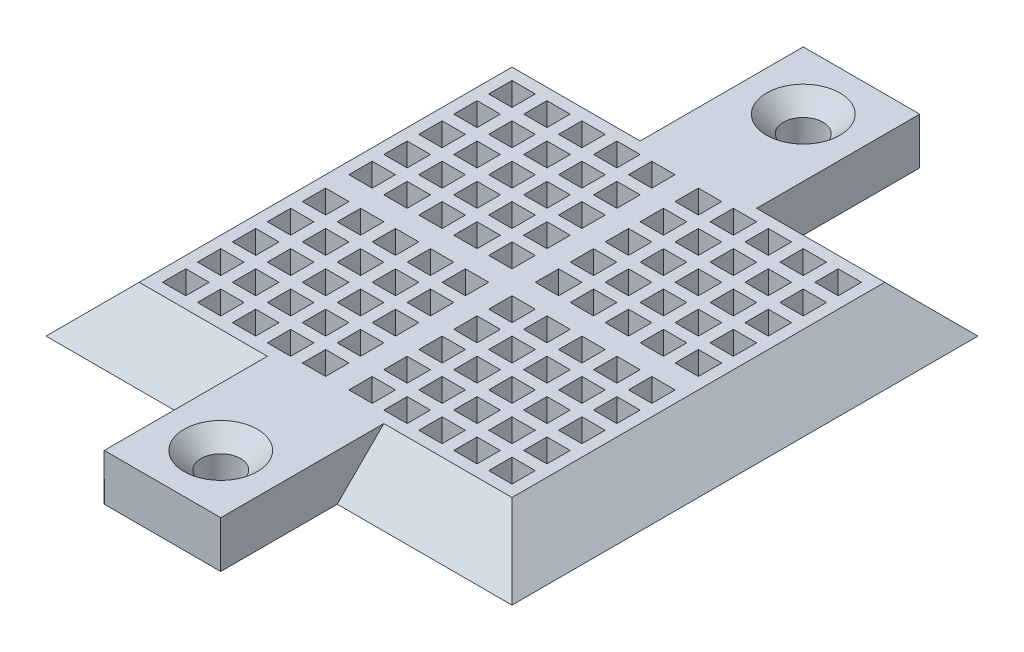
from build123d import *

# Parameters (mm, degrees)
SKETCH_1_W                        = 10
SKETCH_1_H                        = 10
SKETCH_1_W_2                      = 40
SKETCH_1_H_2                      = 40
EXTRUDE_2_DEPTH                   = 4
DRAFT_2_ANGLE                     = -45
HOLE_WIZARD_M31_D                 = 3.4
HOLE_WIZARD_M31_DEPTH             = 4
HOLE_WIZARD_M31_CSINK_D           = 6.3
HOLE_WIZARD_M31_CSINK_ANGLE       = 90
SKETCH_5_W                        = 2
SKETCH_5_H                        = 2
CUT_EXTRUDE_1_DEPTH               = 4
PATTERN_LINEAR_1_COUNT            = 5
PATTERN_LINEAR_1_PITCH            = 3
PATTERN_LINEAR_1_COUNT_DIR2       = 5
PATTERN_LINEAR_1_PITCH_DIR2       = 3
PATTERN_LINEAR_2_COUNT            = 2
PATTERN_LINEAR_2_PITCH            = 16
PATTERN_LINEAR_2_COUNT_DIR2       = 2
PATTERN_LINEAR_2_PITCH_DIR2       = 16
PATTERN_LINEAR_2_COPY_1_SKETCH_W  = 2
PATTERN_LINEAR_2_COPY_1_SKETCH_H  = 2
PATTERN_LINEAR_2_COPY_1_DEPTH     = 4
PATTERN_LINEAR_2_COPY_2_SKETCH_W  = 2
PATTERN_LINEAR_2_COPY_2_SKETCH_H  = 2
PATTERN_LINEAR_2_COPY_2_DEPTH     = 4
PATTERN_LINEAR_2_COPY_3_SKETCH_W  = 2
PATTERN_LINEAR_2_COPY_3_SKETCH_H  = 2
PATTERN_LINEAR_2_COPY_3_DEPTH     = 4
PATTERN_LINEAR_2_COPY_4_SKETCH_W  = 2
PATTERN_LINEAR_2_COPY_4_SKETCH_H  = 2
PATTERN_LINEAR_2_COPY_4_DEPTH     = 4
PATTERN_LINEAR_2_COPY_5_SKETCH_W  = 2
PATTERN_LINEAR_2_COPY_5_SKETCH_H  = 2
PATTERN_LINEAR_2_COPY_5_DEPTH     = 4
PATTERN_LINEAR_2_COPY_6_SKETCH_W  = 2
PATTERN_LINEAR_2_COPY_6_SKETCH_H  = 2
PATTERN_LINEAR_2_COPY_6_DEPTH     = 4
PATTERN_LINEAR_2_COPY_7_SKETCH_W  = 2
PATTERN_LINEAR_2_COPY_7_SKETCH_H  = 2
PATTERN_LINEAR_2_COPY_7_DEPTH     = 4
PATTERN_LINEAR_2_COPY_8_SKETCH_W  = 2
PATTERN_LINEAR_2_COPY_8_SKETCH_H  = 2
PATTERN_LINEAR_2_COPY_8_DEPTH     = 4
PATTERN_LINEAR_2_COPY_9_SKETCH_W  = 2
PATTERN_LINEAR_2_COPY_9_SKETCH_H  = 2
PATTERN_LINEAR_2_COPY_9_DEPTH     = 4
PATTERN_LINEAR_2_COPY_10_SKETCH_W = 2
PATTERN_LINEAR_2_COPY_10_SKETCH_H = 2
PATTERN_LINEAR_2_COPY_10_DEPTH    = 4
PATTERN_LINEAR_2_COPY_11_SKETCH_W = 2
PATTERN_LINEAR_2_COPY_11_SKETCH_H = 2
PATTERN_LINEAR_2_COPY_11_DEPTH    = 4
PATTERN_LINEAR_2_COPY_12_SKETCH_W = 2
PATTERN_LINEAR_2_COPY_12_SKETCH_H = 2
PATTERN_LINEAR_2_COPY_12_DEPTH    = 4
PATTERN_LINEAR_2_COPY_13_SKETCH_W = 2
PATTERN_LINEAR_2_COPY_13_SKETCH_H = 2
PATTERN_LINEAR_2_COPY_13_DEPTH    = 4
PATTERN_LINEAR_2_COPY_14_SKETCH_W = 2
PATTERN_LINEAR_2_COPY_14_SKETCH_H = 2
PATTERN_LINEAR_2_COPY_14_DEPTH    = 4
PATTERN_LINEAR_2_COPY_15_SKETCH_W = 2
PATTERN_LINEAR_2_COPY_15_SKETCH_H = 2
PATTERN_LINEAR_2_COPY_15_DEPTH    = 4
PATTERN_LINEAR_2_COPY_16_SKETCH_W = 2
PATTERN_LINEAR_2_COPY_16_SKETCH_H = 2
PATTERN_LINEAR_2_COPY_16_DEPTH    = 4
PATTERN_LINEAR_2_COPY_17_SKETCH_W = 2
PATTERN_LINEAR_2_COPY_17_SKETCH_H = 2
PATTERN_LINEAR_2_COPY_17_DEPTH    = 4
PATTERN_LINEAR_2_COPY_18_SKETCH_W = 2
PATTERN_LINEAR_2_COPY_18_SKETCH_H = 2
PATTERN_LINEAR_2_COPY_18_DEPTH    = 4
PATTERN_LINEAR_2_COPY_19_SKETCH_W = 2
PATTERN_LINEAR_2_COPY_19_SKETCH_H = 2
PATTERN_LINEAR_2_COPY_19_DEPTH    = 4
PATTERN_LINEAR_2_COPY_20_SKETCH_W = 2
PATTERN_LINEAR_2_COPY_20_SKETCH_H = 2
PATTERN_LINEAR_2_COPY_20_DEPTH    = 4
PATTERN_LINEAR_2_COPY_21_SKETCH_W = 2
PATTERN_LINEAR_2_COPY_21_SKETCH_H = 2
PATTERN_LINEAR_2_COPY_21_DEPTH    = 4
PATTERN_LINEAR_2_COPY_22_SKETCH_W = 2
PATTERN_LINEAR_2_COPY_22_SKETCH_H = 2
PATTERN_LINEAR_2_COPY_22_DEPTH    = 4
PATTERN_LINEAR_2_COPY_23_SKETCH_W = 2
PATTERN_LINEAR_2_COPY_23_SKETCH_H = 2
PATTERN_LINEAR_2_COPY_23_DEPTH    = 4
PATTERN_LINEAR_2_COPY_24_SKETCH_W = 2
PATTERN_LINEAR_2_COPY_24_SKETCH_H = 2
PATTERN_LINEAR_2_COPY_24_DEPTH    = 4
PATTERN_LINEAR_2_COPY_25_SKETCH_W = 2
PATTERN_LINEAR_2_COPY_25_SKETCH_H = 2
PATTERN_LINEAR_2_COPY_25_DEPTH    = 4
PATTERN_LINEAR_2_COPY_26_SKETCH_W = 2
PATTERN_LINEAR_2_COPY_26_SKETCH_H = 2
PATTERN_LINEAR_2_COPY_26_DEPTH    = 4
PATTERN_LINEAR_2_COPY_27_SKETCH_W = 2
PATTERN_LINEAR_2_COPY_27_SKETCH_H = 2
PATTERN_LINEAR_2_COPY_27_DEPTH    = 4
PATTERN_LINEAR_2_COPY_28_SKETCH_W = 2
PATTERN_LINEAR_2_COPY_28_SKETCH_H = 2
PATTERN_LINEAR_2_COPY_28_DEPTH    = 4
PATTERN_LINEAR_2_COPY_29_SKETCH_W = 2
PATTERN_LINEAR_2_COPY_29_SKETCH_H = 2
PATTERN_LINEAR_2_COPY_29_DEPTH    = 4
PATTERN_LINEAR_2_COPY_30_SKETCH_W = 2
PATTERN_LINEAR_2_COPY_30_SKETCH_H = 2
PATTERN_LINEAR_2_COPY_30_DEPTH    = 4
PATTERN_LINEAR_2_COPY_31_SKETCH_W = 2
PATTERN_LINEAR_2_COPY_31_SKETCH_H = 2
PATTERN_LINEAR_2_COPY_31_DEPTH    = 4
PATTERN_LINEAR_2_COPY_32_SKETCH_W = 2
PATTERN_LINEAR_2_COPY_32_SKETCH_H = 2
PATTERN_LINEAR_2_COPY_32_DEPTH    = 4
PATTERN_LINEAR_2_COPY_33_SKETCH_W = 2
PATTERN_LINEAR_2_COPY_33_SKETCH_H = 2
PATTERN_LINEAR_2_COPY_33_DEPTH    = 4
PATTERN_LINEAR_2_COPY_34_SKETCH_W = 2
PATTERN_LINEAR_2_COPY_34_SKETCH_H = 2
PATTERN_LINEAR_2_COPY_34_DEPTH    = 4
PATTERN_LINEAR_2_COPY_35_SKETCH_W = 2
PATTERN_LINEAR_2_COPY_35_SKETCH_H = 2
PATTERN_LINEAR_2_COPY_35_DEPTH    = 4
PATTERN_LINEAR_2_COPY_36_SKETCH_W = 2
PATTERN_LINEAR_2_COPY_36_SKETCH_H = 2
PATTERN_LINEAR_2_COPY_36_DEPTH    = 4
PATTERN_LINEAR_2_COPY_37_SKETCH_W = 2
PATTERN_LINEAR_2_COPY_37_SKETCH_H = 2
PATTERN_LINEAR_2_COPY_37_DEPTH    = 4
PATTERN_LINEAR_2_COPY_38_SKETCH_W = 2
PATTERN_LINEAR_2_COPY_38_SKETCH_H = 2
PATTERN_LINEAR_2_COPY_38_DEPTH    = 4
PATTERN_LINEAR_2_COPY_39_SKETCH_W = 2
PATTERN_LINEAR_2_COPY_39_SKETCH_H = 2
PATTERN_LINEAR_2_COPY_39_DEPTH    = 4
PATTERN_LINEAR_2_COPY_40_SKETCH_W = 2
PATTERN_LINEAR_2_COPY_40_SKETCH_H = 2
PATTERN_LINEAR_2_COPY_40_DEPTH    = 4
PATTERN_LINEAR_2_COPY_41_SKETCH_W = 2
PATTERN_LINEAR_2_COPY_41_SKETCH_H = 2
PATTERN_LINEAR_2_COPY_41_DEPTH    = 4
PATTERN_LINEAR_2_COPY_42_SKETCH_W = 2
PATTERN_LINEAR_2_COPY_42_SKETCH_H = 2
PATTERN_LINEAR_2_COPY_42_DEPTH    = 4
PATTERN_LINEAR_2_COPY_43_SKETCH_W = 2
PATTERN_LINEAR_2_COPY_43_SKETCH_H = 2
PATTERN_LINEAR_2_COPY_43_DEPTH    = 4
PATTERN_LINEAR_2_COPY_44_SKETCH_W = 2
PATTERN_LINEAR_2_COPY_44_SKETCH_H = 2
PATTERN_LINEAR_2_COPY_44_DEPTH    = 4
PATTERN_LINEAR_2_COPY_45_SKETCH_W = 2
PATTERN_LINEAR_2_COPY_45_SKETCH_H = 2
PATTERN_LINEAR_2_COPY_45_DEPTH    = 4
PATTERN_LINEAR_2_COPY_46_SKETCH_W = 2
PATTERN_LINEAR_2_COPY_46_SKETCH_H = 2
PATTERN_LINEAR_2_COPY_46_DEPTH    = 4
PATTERN_LINEAR_2_COPY_47_SKETCH_W = 2
PATTERN_LINEAR_2_COPY_47_SKETCH_H = 2
PATTERN_LINEAR_2_COPY_47_DEPTH    = 4
PATTERN_LINEAR_2_COPY_48_SKETCH_W = 2
PATTERN_LINEAR_2_COPY_48_SKETCH_H = 2
PATTERN_LINEAR_2_COPY_48_DEPTH    = 4
PATTERN_LINEAR_2_COPY_49_SKETCH_W = 2
PATTERN_LINEAR_2_COPY_49_SKETCH_H = 2
PATTERN_LINEAR_2_COPY_49_DEPTH    = 4
PATTERN_LINEAR_2_COPY_50_SKETCH_W = 2
PATTERN_LINEAR_2_COPY_50_SKETCH_H = 2
PATTERN_LINEAR_2_COPY_50_DEPTH    = 4
PATTERN_LINEAR_2_COPY_51_SKETCH_W = 2
PATTERN_LINEAR_2_COPY_51_SKETCH_H = 2
PATTERN_LINEAR_2_COPY_51_DEPTH    = 4
PATTERN_LINEAR_2_COPY_52_SKETCH_W = 2
PATTERN_LINEAR_2_COPY_52_SKETCH_H = 2
PATTERN_LINEAR_2_COPY_52_DEPTH    = 4
PATTERN_LINEAR_2_COPY_53_SKETCH_W = 2
PATTERN_LINEAR_2_COPY_53_SKETCH_H = 2
PATTERN_LINEAR_2_COPY_53_DEPTH    = 4
PATTERN_LINEAR_2_COPY_54_SKETCH_W = 2
PATTERN_LINEAR_2_COPY_54_SKETCH_H = 2
PATTERN_LINEAR_2_COPY_54_DEPTH    = 4
PATTERN_LINEAR_2_COPY_55_SKETCH_W = 2
PATTERN_LINEAR_2_COPY_55_SKETCH_H = 2
PATTERN_LINEAR_2_COPY_55_DEPTH    = 4
PATTERN_LINEAR_2_COPY_56_SKETCH_W = 2
PATTERN_LINEAR_2_COPY_56_SKETCH_H = 2
PATTERN_LINEAR_2_COPY_56_DEPTH    = 4
PATTERN_LINEAR_2_COPY_57_SKETCH_W = 2
PATTERN_LINEAR_2_COPY_57_SKETCH_H = 2
PATTERN_LINEAR_2_COPY_57_DEPTH    = 4
PATTERN_LINEAR_2_COPY_58_SKETCH_W = 2
PATTERN_LINEAR_2_COPY_58_SKETCH_H = 2
PATTERN_LINEAR_2_COPY_58_DEPTH    = 4
PATTERN_LINEAR_2_COPY_59_SKETCH_W = 2
PATTERN_LINEAR_2_COPY_59_SKETCH_H = 2
PATTERN_LINEAR_2_COPY_59_DEPTH    = 4
PATTERN_LINEAR_2_COPY_60_SKETCH_W = 2
PATTERN_LINEAR_2_COPY_60_SKETCH_H = 2
PATTERN_LINEAR_2_COPY_60_DEPTH    = 4
PATTERN_LINEAR_2_COPY_61_SKETCH_W = 2
PATTERN_LINEAR_2_COPY_61_SKETCH_H = 2
PATTERN_LINEAR_2_COPY_61_DEPTH    = 4
PATTERN_LINEAR_2_COPY_62_SKETCH_W = 2
PATTERN_LINEAR_2_COPY_62_SKETCH_H = 2
PATTERN_LINEAR_2_COPY_62_DEPTH    = 4
PATTERN_LINEAR_2_COPY_63_SKETCH_W = 2
PATTERN_LINEAR_2_COPY_63_SKETCH_H = 2
PATTERN_LINEAR_2_COPY_63_DEPTH    = 4
PATTERN_LINEAR_2_COPY_64_SKETCH_W = 2
PATTERN_LINEAR_2_COPY_64_SKETCH_H = 2
PATTERN_LINEAR_2_COPY_64_DEPTH    = 4
PATTERN_LINEAR_2_COPY_65_SKETCH_W = 2
PATTERN_LINEAR_2_COPY_65_SKETCH_H = 2
PATTERN_LINEAR_2_COPY_65_DEPTH    = 4
PATTERN_LINEAR_2_COPY_66_SKETCH_W = 2
PATTERN_LINEAR_2_COPY_66_SKETCH_H = 2
PATTERN_LINEAR_2_COPY_66_DEPTH    = 4
PATTERN_LINEAR_2_COPY_67_SKETCH_W = 2
PATTERN_LINEAR_2_COPY_67_SKETCH_H = 2
PATTERN_LINEAR_2_COPY_67_DEPTH    = 4
PATTERN_LINEAR_2_COPY_68_SKETCH_W = 2
PATTERN_LINEAR_2_COPY_68_SKETCH_H = 2
PATTERN_LINEAR_2_COPY_68_DEPTH    = 4
PATTERN_LINEAR_2_COPY_69_SKETCH_W = 2
PATTERN_LINEAR_2_COPY_69_SKETCH_H = 2
PATTERN_LINEAR_2_COPY_69_DEPTH    = 4
PATTERN_LINEAR_2_COPY_70_SKETCH_W = 2
PATTERN_LINEAR_2_COPY_70_SKETCH_H = 2
PATTERN_LINEAR_2_COPY_70_DEPTH    = 4
PATTERN_LINEAR_2_COPY_71_SKETCH_W = 2
PATTERN_LINEAR_2_COPY_71_SKETCH_H = 2
PATTERN_LINEAR_2_COPY_71_DEPTH    = 4
PATTERN_LINEAR_2_COPY_72_SKETCH_W = 2
PATTERN_LINEAR_2_COPY_72_SKETCH_H = 2
PATTERN_LINEAR_2_COPY_72_DEPTH    = 4


with BuildPart() as part:
    # Эскиз1 → Бобышка-Вытянуть2 (new body)
    with BuildSketch(Plane(origin=(0, 0, 0), x_dir=(1, 0, 0), z_dir=(0, 1, 0))):
        with Locations((0, 25)):
            Rectangle(SKETCH_1_W, SKETCH_1_H)
        Rectangle(SKETCH_1_W_2, SKETCH_1_H_2)
        with Locations((0, -25)):
            Rectangle(SKETCH_1_W, SKETCH_1_H)
    extrude(amount=EXTRUDE_2_DEPTH)

    # Уклон2
    draft_2_faces = [part.faces().sort_by_distance(p)[0] for p in [
        (-12.5, 2, 20),
        (-20, 2, 0),
        (-12.5, 2, -20),
        (12.5, 2, -20),
        (20, 2, 0),
        (12.5, 2, 20),
    ]]
    draft(draft_2_faces, Plane(origin=(0, 0, 0), x_dir=(0, 0, -1), z_dir=(0, -1, 0)), DRAFT_2_ANGLE)

    # Зенковка для винта с потайной головкой M31
    with Locations(Plane(origin=(0, 4, -25), x_dir=(0, 0, 1), z_dir=(0, 1, 0))):
        with Locations((0, 0)):
            hole_wizard_m31 = CounterSinkHole(HOLE_WIZARD_M31_D / 2, HOLE_WIZARD_M31_CSINK_D / 2, depth=HOLE_WIZARD_M31_DEPTH, counter_sink_angle=HOLE_WIZARD_M31_CSINK_ANGLE)

    # Зеркальное отражение1: Зенковка для винта с потайной головкой M31 across plane
    add(hole_wizard_m31.mirror(Plane.XY), mode=Mode.SUBTRACT)

    # Эскиз5 → Вырез-Вытянуть1 (cut)
    with BuildSketch(Plane(origin=(0, 4, 0), x_dir=(1, 0, 0), z_dir=(0, 1, 0))):
        with Locations((14, 14)):
            Rectangle(SKETCH_5_W, SKETCH_5_H)
    cut_extrude_1 = extrude(amount=-CUT_EXTRUDE_1_DEPTH, mode=Mode.SUBTRACT)

    # Линейный массив1: Cut-Extrude 1 5 × 5
    with Locations(*[(-i * PATTERN_LINEAR_1_PITCH, 0, j * PATTERN_LINEAR_1_PITCH_DIR2) for i in range(PATTERN_LINEAR_1_COUNT) for j in range(PATTERN_LINEAR_1_COUNT_DIR2) if (i, j) != (0, 0)]):
        add(cut_extrude_1, mode=Mode.SUBTRACT)

    # Линейный массив2: Cut-Extrude 1 2 × 2
    with Locations(*[(-i * PATTERN_LINEAR_2_PITCH, 0, j * PATTERN_LINEAR_2_PITCH_DIR2) for i in range(PATTERN_LINEAR_2_COUNT) for j in range(PATTERN_LINEAR_2_COUNT_DIR2) if (i, j) != (0, 0)]):
        add(cut_extrude_1, mode=Mode.SUBTRACT)

    # Линейный массив2 copy 1 sketch → Линейный массив2 copy 1 (cut)
    with BuildSketch(Plane(origin=(0, 4, 19), x_dir=(1, 0, 0), z_dir=(0, 1, 0))):
        with Locations((14, 14)):
            Rectangle(PATTERN_LINEAR_2_COPY_1_SKETCH_W, PATTERN_LINEAR_2_COPY_1_SKETCH_H)
    extrude(amount=-PATTERN_LINEAR_2_COPY_1_DEPTH, mode=Mode.SUBTRACT)

    # Линейный массив2 copy 2 sketch → Линейный массив2 copy 2 (cut)
    with BuildSketch(Plane(origin=(-16, 4, 3), x_dir=(1, 0, 0), z_dir=(0, 1, 0))):
        with Locations((14, 14)):
            Rectangle(PATTERN_LINEAR_2_COPY_2_SKETCH_W, PATTERN_LINEAR_2_COPY_2_SKETCH_H)
    extrude(amount=-PATTERN_LINEAR_2_COPY_2_DEPTH, mode=Mode.SUBTRACT)

    # Линейный массив2 copy 3 sketch → Линейный массив2 copy 3 (cut)
    with BuildSketch(Plane(origin=(-16, 4, 19), x_dir=(1, 0, 0), z_dir=(0, 1, 0))):
        with Locations((14, 14)):
            Rectangle(PATTERN_LINEAR_2_COPY_3_SKETCH_W, PATTERN_LINEAR_2_COPY_3_SKETCH_H)
    extrude(amount=-PATTERN_LINEAR_2_COPY_3_DEPTH, mode=Mode.SUBTRACT)

    # Линейный массив2 copy 4 sketch → Линейный массив2 copy 4 (cut)
    with BuildSketch(Plane(origin=(0, 4, 22), x_dir=(1, 0, 0), z_dir=(0, 1, 0))):
        with Locations((14, 14)):
            Rectangle(PATTERN_LINEAR_2_COPY_4_SKETCH_W, PATTERN_LINEAR_2_COPY_4_SKETCH_H)
    extrude(amount=-PATTERN_LINEAR_2_COPY_4_DEPTH, mode=Mode.SUBTRACT)

    # Линейный массив2 copy 5 sketch → Линейный массив2 copy 5 (cut)
    with BuildSketch(Plane(origin=(-16, 4, 6), x_dir=(1, 0, 0), z_dir=(0, 1, 0))):
        with Locations((14, 14)):
            Rectangle(PATTERN_LINEAR_2_COPY_5_SKETCH_W, PATTERN_LINEAR_2_COPY_5_SKETCH_H)
    extrude(amount=-PATTERN_LINEAR_2_COPY_5_DEPTH, mode=Mode.SUBTRACT)

    # Линейный массив2 copy 6 sketch → Линейный массив2 copy 6 (cut)
    with BuildSketch(Plane(origin=(-16, 4, 22), x_dir=(1, 0, 0), z_dir=(0, 1, 0))):
        with Locations((14, 14)):
            Rectangle(PATTERN_LINEAR_2_COPY_6_SKETCH_W, PATTERN_LINEAR_2_COPY_6_SKETCH_H)
    extrude(amount=-PATTERN_LINEAR_2_COPY_6_DEPTH, mode=Mode.SUBTRACT)

    # Линейный массив2 copy 7 sketch → Линейный массив2 copy 7 (cut)
    with BuildSketch(Plane(origin=(0, 4, 25), x_dir=(1, 0, 0), z_dir=(0, 1, 0))):
        with Locations((14, 14)):
            Rectangle(PATTERN_LINEAR_2_COPY_7_SKETCH_W, PATTERN_LINEAR_2_COPY_7_SKETCH_H)
    extrude(amount=-PATTERN_LINEAR_2_COPY_7_DEPTH, mode=Mode.SUBTRACT)

    # Линейный массив2 copy 8 sketch → Линейный массив2 copy 8 (cut)
    with BuildSketch(Plane(origin=(-16, 4, 9), x_dir=(1, 0, 0), z_dir=(0, 1, 0))):
        with Locations((14, 14)):
            Rectangle(PATTERN_LINEAR_2_COPY_8_SKETCH_W, PATTERN_LINEAR_2_COPY_8_SKETCH_H)
    extrude(amount=-PATTERN_LINEAR_2_COPY_8_DEPTH, mode=Mode.SUBTRACT)

    # Линейный массив2 copy 9 sketch → Линейный массив2 copy 9 (cut)
    with BuildSketch(Plane(origin=(-16, 4, 25), x_dir=(1, 0, 0), z_dir=(0, 1, 0))):
        with Locations((14, 14)):
            Rectangle(PATTERN_LINEAR_2_COPY_9_SKETCH_W, PATTERN_LINEAR_2_COPY_9_SKETCH_H)
    extrude(amount=-PATTERN_LINEAR_2_COPY_9_DEPTH, mode=Mode.SUBTRACT)

    # Линейный массив2 copy 10 sketch → Линейный массив2 copy 10 (cut)
    with BuildSketch(Plane(origin=(0, 4, 28), x_dir=(1, 0, 0), z_dir=(0, 1, 0))):
        with Locations((14, 14)):
            Rectangle(PATTERN_LINEAR_2_COPY_10_SKETCH_W, PATTERN_LINEAR_2_COPY_10_SKETCH_H)
    extrude(amount=-PATTERN_LINEAR_2_COPY_10_DEPTH, mode=Mode.SUBTRACT)

    # Линейный массив2 copy 11 sketch → Линейный массив2 copy 11 (cut)
    with BuildSketch(Plane(origin=(-16, 4, 12), x_dir=(1, 0, 0), z_dir=(0, 1, 0))):
        with Locations((14, 14)):
            Rectangle(PATTERN_LINEAR_2_COPY_11_SKETCH_W, PATTERN_LINEAR_2_COPY_11_SKETCH_H)
    extrude(amount=-PATTERN_LINEAR_2_COPY_11_DEPTH, mode=Mode.SUBTRACT)

    # Линейный массив2 copy 12 sketch → Линейный массив2 copy 12 (cut)
    with BuildSketch(Plane(origin=(-16, 4, 28), x_dir=(1, 0, 0), z_dir=(0, 1, 0))):
        with Locations((14, 14)):
            Rectangle(PATTERN_LINEAR_2_COPY_12_SKETCH_W, PATTERN_LINEAR_2_COPY_12_SKETCH_H)
    extrude(amount=-PATTERN_LINEAR_2_COPY_12_DEPTH, mode=Mode.SUBTRACT)

    # Линейный массив2 copy 13 sketch → Линейный массив2 copy 13 (cut)
    with BuildSketch(Plane(origin=(-3, 4, 16), x_dir=(1, 0, 0), z_dir=(0, 1, 0))):
        with Locations((14, 14)):
            Rectangle(PATTERN_LINEAR_2_COPY_13_SKETCH_W, PATTERN_LINEAR_2_COPY_13_SKETCH_H)
    extrude(amount=-PATTERN_LINEAR_2_COPY_13_DEPTH, mode=Mode.SUBTRACT)

    # Линейный массив2 copy 14 sketch → Линейный массив2 copy 14 (cut)
    with BuildSketch(Plane(origin=(-19, 4, 0), x_dir=(1, 0, 0), z_dir=(0, 1, 0))):
        with Locations((14, 14)):
            Rectangle(PATTERN_LINEAR_2_COPY_14_SKETCH_W, PATTERN_LINEAR_2_COPY_14_SKETCH_H)
    extrude(amount=-PATTERN_LINEAR_2_COPY_14_DEPTH, mode=Mode.SUBTRACT)

    # Линейный массив2 copy 15 sketch → Линейный массив2 copy 15 (cut)
    with BuildSketch(Plane(origin=(-19, 4, 16), x_dir=(1, 0, 0), z_dir=(0, 1, 0))):
        with Locations((14, 14)):
            Rectangle(PATTERN_LINEAR_2_COPY_15_SKETCH_W, PATTERN_LINEAR_2_COPY_15_SKETCH_H)
    extrude(amount=-PATTERN_LINEAR_2_COPY_15_DEPTH, mode=Mode.SUBTRACT)

    # Линейный массив2 copy 16 sketch → Линейный массив2 copy 16 (cut)
    with BuildSketch(Plane(origin=(-3, 4, 19), x_dir=(1, 0, 0), z_dir=(0, 1, 0))):
        with Locations((14, 14)):
            Rectangle(PATTERN_LINEAR_2_COPY_16_SKETCH_W, PATTERN_LINEAR_2_COPY_16_SKETCH_H)
    extrude(amount=-PATTERN_LINEAR_2_COPY_16_DEPTH, mode=Mode.SUBTRACT)

    # Линейный массив2 copy 17 sketch → Линейный массив2 copy 17 (cut)
    with BuildSketch(Plane(origin=(-19, 4, 3), x_dir=(1, 0, 0), z_dir=(0, 1, 0))):
        with Locations((14, 14)):
            Rectangle(PATTERN_LINEAR_2_COPY_17_SKETCH_W, PATTERN_LINEAR_2_COPY_17_SKETCH_H)
    extrude(amount=-PATTERN_LINEAR_2_COPY_17_DEPTH, mode=Mode.SUBTRACT)

    # Линейный массив2 copy 18 sketch → Линейный массив2 copy 18 (cut)
    with BuildSketch(Plane(origin=(-19, 4, 19), x_dir=(1, 0, 0), z_dir=(0, 1, 0))):
        with Locations((14, 14)):
            Rectangle(PATTERN_LINEAR_2_COPY_18_SKETCH_W, PATTERN_LINEAR_2_COPY_18_SKETCH_H)
    extrude(amount=-PATTERN_LINEAR_2_COPY_18_DEPTH, mode=Mode.SUBTRACT)

    # Линейный массив2 copy 19 sketch → Линейный массив2 copy 19 (cut)
    with BuildSketch(Plane(origin=(-3, 4, 22), x_dir=(1, 0, 0), z_dir=(0, 1, 0))):
        with Locations((14, 14)):
            Rectangle(PATTERN_LINEAR_2_COPY_19_SKETCH_W, PATTERN_LINEAR_2_COPY_19_SKETCH_H)
    extrude(amount=-PATTERN_LINEAR_2_COPY_19_DEPTH, mode=Mode.SUBTRACT)

    # Линейный массив2 copy 20 sketch → Линейный массив2 copy 20 (cut)
    with BuildSketch(Plane(origin=(-19, 4, 6), x_dir=(1, 0, 0), z_dir=(0, 1, 0))):
        with Locations((14, 14)):
            Rectangle(PATTERN_LINEAR_2_COPY_20_SKETCH_W, PATTERN_LINEAR_2_COPY_20_SKETCH_H)
    extrude(amount=-PATTERN_LINEAR_2_COPY_20_DEPTH, mode=Mode.SUBTRACT)

    # Линейный массив2 copy 21 sketch → Линейный массив2 copy 21 (cut)
    with BuildSketch(Plane(origin=(-19, 4, 22), x_dir=(1, 0, 0), z_dir=(0, 1, 0))):
        with Locations((14, 14)):
            Rectangle(PATTERN_LINEAR_2_COPY_21_SKETCH_W, PATTERN_LINEAR_2_COPY_21_SKETCH_H)
    extrude(amount=-PATTERN_LINEAR_2_COPY_21_DEPTH, mode=Mode.SUBTRACT)

    # Линейный массив2 copy 22 sketch → Линейный массив2 copy 22 (cut)
    with BuildSketch(Plane(origin=(-3, 4, 25), x_dir=(1, 0, 0), z_dir=(0, 1, 0))):
        with Locations((14, 14)):
            Rectangle(PATTERN_LINEAR_2_COPY_22_SKETCH_W, PATTERN_LINEAR_2_COPY_22_SKETCH_H)
    extrude(amount=-PATTERN_LINEAR_2_COPY_22_DEPTH, mode=Mode.SUBTRACT)

    # Линейный массив2 copy 23 sketch → Линейный массив2 copy 23 (cut)
    with BuildSketch(Plane(origin=(-19, 4, 9), x_dir=(1, 0, 0), z_dir=(0, 1, 0))):
        with Locations((14, 14)):
            Rectangle(PATTERN_LINEAR_2_COPY_23_SKETCH_W, PATTERN_LINEAR_2_COPY_23_SKETCH_H)
    extrude(amount=-PATTERN_LINEAR_2_COPY_23_DEPTH, mode=Mode.SUBTRACT)

    # Линейный массив2 copy 24 sketch → Линейный массив2 copy 24 (cut)
    with BuildSketch(Plane(origin=(-19, 4, 25), x_dir=(1, 0, 0), z_dir=(0, 1, 0))):
        with Locations((14, 14)):
            Rectangle(PATTERN_LINEAR_2_COPY_24_SKETCH_W, PATTERN_LINEAR_2_COPY_24_SKETCH_H)
    extrude(amount=-PATTERN_LINEAR_2_COPY_24_DEPTH, mode=Mode.SUBTRACT)

    # Линейный массив2 copy 25 sketch → Линейный массив2 copy 25 (cut)
    with BuildSketch(Plane(origin=(-3, 4, 28), x_dir=(1, 0, 0), z_dir=(0, 1, 0))):
        with Locations((14, 14)):
            Rectangle(PATTERN_LINEAR_2_COPY_25_SKETCH_W, PATTERN_LINEAR_2_COPY_25_SKETCH_H)
    extrude(amount=-PATTERN_LINEAR_2_COPY_25_DEPTH, mode=Mode.SUBTRACT)

    # Линейный массив2 copy 26 sketch → Линейный массив2 copy 26 (cut)
    with BuildSketch(Plane(origin=(-19, 4, 12), x_dir=(1, 0, 0), z_dir=(0, 1, 0))):
        with Locations((14, 14)):
            Rectangle(PATTERN_LINEAR_2_COPY_26_SKETCH_W, PATTERN_LINEAR_2_COPY_26_SKETCH_H)
    extrude(amount=-PATTERN_LINEAR_2_COPY_26_DEPTH, mode=Mode.SUBTRACT)

    # Линейный массив2 copy 27 sketch → Линейный массив2 copy 27 (cut)
    with BuildSketch(Plane(origin=(-19, 4, 28), x_dir=(1, 0, 0), z_dir=(0, 1, 0))):
        with Locations((14, 14)):
            Rectangle(PATTERN_LINEAR_2_COPY_27_SKETCH_W, PATTERN_LINEAR_2_COPY_27_SKETCH_H)
    extrude(amount=-PATTERN_LINEAR_2_COPY_27_DEPTH, mode=Mode.SUBTRACT)

    # Линейный массив2 copy 28 sketch → Линейный массив2 copy 28 (cut)
    with BuildSketch(Plane(origin=(-6, 4, 16), x_dir=(1, 0, 0), z_dir=(0, 1, 0))):
        with Locations((14, 14)):
            Rectangle(PATTERN_LINEAR_2_COPY_28_SKETCH_W, PATTERN_LINEAR_2_COPY_28_SKETCH_H)
    extrude(amount=-PATTERN_LINEAR_2_COPY_28_DEPTH, mode=Mode.SUBTRACT)

    # Линейный массив2 copy 29 sketch → Линейный массив2 copy 29 (cut)
    with BuildSketch(Plane(origin=(-22, 4, 0), x_dir=(1, 0, 0), z_dir=(0, 1, 0))):
        with Locations((14, 14)):
            Rectangle(PATTERN_LINEAR_2_COPY_29_SKETCH_W, PATTERN_LINEAR_2_COPY_29_SKETCH_H)
    extrude(amount=-PATTERN_LINEAR_2_COPY_29_DEPTH, mode=Mode.SUBTRACT)

    # Линейный массив2 copy 30 sketch → Линейный массив2 copy 30 (cut)
    with BuildSketch(Plane(origin=(-22, 4, 16), x_dir=(1, 0, 0), z_dir=(0, 1, 0))):
        with Locations((14, 14)):
            Rectangle(PATTERN_LINEAR_2_COPY_30_SKETCH_W, PATTERN_LINEAR_2_COPY_30_SKETCH_H)
    extrude(amount=-PATTERN_LINEAR_2_COPY_30_DEPTH, mode=Mode.SUBTRACT)

    # Линейный массив2 copy 31 sketch → Линейный массив2 copy 31 (cut)
    with BuildSketch(Plane(origin=(-6, 4, 19), x_dir=(1, 0, 0), z_dir=(0, 1, 0))):
        with Locations((14, 14)):
            Rectangle(PATTERN_LINEAR_2_COPY_31_SKETCH_W, PATTERN_LINEAR_2_COPY_31_SKETCH_H)
    extrude(amount=-PATTERN_LINEAR_2_COPY_31_DEPTH, mode=Mode.SUBTRACT)

    # Линейный массив2 copy 32 sketch → Линейный массив2 copy 32 (cut)
    with BuildSketch(Plane(origin=(-22, 4, 3), x_dir=(1, 0, 0), z_dir=(0, 1, 0))):
        with Locations((14, 14)):
            Rectangle(PATTERN_LINEAR_2_COPY_32_SKETCH_W, PATTERN_LINEAR_2_COPY_32_SKETCH_H)
    extrude(amount=-PATTERN_LINEAR_2_COPY_32_DEPTH, mode=Mode.SUBTRACT)

    # Линейный массив2 copy 33 sketch → Линейный массив2 copy 33 (cut)
    with BuildSketch(Plane(origin=(-22, 4, 19), x_dir=(1, 0, 0), z_dir=(0, 1, 0))):
        with Locations((14, 14)):
            Rectangle(PATTERN_LINEAR_2_COPY_33_SKETCH_W, PATTERN_LINEAR_2_COPY_33_SKETCH_H)
    extrude(amount=-PATTERN_LINEAR_2_COPY_33_DEPTH, mode=Mode.SUBTRACT)

    # Линейный массив2 copy 34 sketch → Линейный массив2 copy 34 (cut)
    with BuildSketch(Plane(origin=(-6, 4, 22), x_dir=(1, 0, 0), z_dir=(0, 1, 0))):
        with Locations((14, 14)):
            Rectangle(PATTERN_LINEAR_2_COPY_34_SKETCH_W, PATTERN_LINEAR_2_COPY_34_SKETCH_H)
    extrude(amount=-PATTERN_LINEAR_2_COPY_34_DEPTH, mode=Mode.SUBTRACT)

    # Линейный массив2 copy 35 sketch → Линейный массив2 copy 35 (cut)
    with BuildSketch(Plane(origin=(-22, 4, 6), x_dir=(1, 0, 0), z_dir=(0, 1, 0))):
        with Locations((14, 14)):
            Rectangle(PATTERN_LINEAR_2_COPY_35_SKETCH_W, PATTERN_LINEAR_2_COPY_35_SKETCH_H)
    extrude(amount=-PATTERN_LINEAR_2_COPY_35_DEPTH, mode=Mode.SUBTRACT)

    # Линейный массив2 copy 36 sketch → Линейный массив2 copy 36 (cut)
    with BuildSketch(Plane(origin=(-22, 4, 22), x_dir=(1, 0, 0), z_dir=(0, 1, 0))):
        with Locations((14, 14)):
            Rectangle(PATTERN_LINEAR_2_COPY_36_SKETCH_W, PATTERN_LINEAR_2_COPY_36_SKETCH_H)
    extrude(amount=-PATTERN_LINEAR_2_COPY_36_DEPTH, mode=Mode.SUBTRACT)

    # Линейный массив2 copy 37 sketch → Линейный массив2 copy 37 (cut)
    with BuildSketch(Plane(origin=(-6, 4, 25), x_dir=(1, 0, 0), z_dir=(0, 1, 0))):
        with Locations((14, 14)):
            Rectangle(PATTERN_LINEAR_2_COPY_37_SKETCH_W, PATTERN_LINEAR_2_COPY_37_SKETCH_H)
    extrude(amount=-PATTERN_LINEAR_2_COPY_37_DEPTH, mode=Mode.SUBTRACT)

    # Линейный массив2 copy 38 sketch → Линейный массив2 copy 38 (cut)
    with BuildSketch(Plane(origin=(-22, 4, 9), x_dir=(1, 0, 0), z_dir=(0, 1, 0))):
        with Locations((14, 14)):
            Rectangle(PATTERN_LINEAR_2_COPY_38_SKETCH_W, PATTERN_LINEAR_2_COPY_38_SKETCH_H)
    extrude(amount=-PATTERN_LINEAR_2_COPY_38_DEPTH, mode=Mode.SUBTRACT)

    # Линейный массив2 copy 39 sketch → Линейный массив2 copy 39 (cut)
    with BuildSketch(Plane(origin=(-22, 4, 25), x_dir=(1, 0, 0), z_dir=(0, 1, 0))):
        with Locations((14, 14)):
            Rectangle(PATTERN_LINEAR_2_COPY_39_SKETCH_W, PATTERN_LINEAR_2_COPY_39_SKETCH_H)
    extrude(amount=-PATTERN_LINEAR_2_COPY_39_DEPTH, mode=Mode.SUBTRACT)

    # Линейный массив2 copy 40 sketch → Линейный массив2 copy 40 (cut)
    with BuildSketch(Plane(origin=(-6, 4, 28), x_dir=(1, 0, 0), z_dir=(0, 1, 0))):
        with Locations((14, 14)):
            Rectangle(PATTERN_LINEAR_2_COPY_40_SKETCH_W, PATTERN_LINEAR_2_COPY_40_SKETCH_H)
    extrude(amount=-PATTERN_LINEAR_2_COPY_40_DEPTH, mode=Mode.SUBTRACT)

    # Линейный массив2 copy 41 sketch → Линейный массив2 copy 41 (cut)
    with BuildSketch(Plane(origin=(-22, 4, 12), x_dir=(1, 0, 0), z_dir=(0, 1, 0))):
        with Locations((14, 14)):
            Rectangle(PATTERN_LINEAR_2_COPY_41_SKETCH_W, PATTERN_LINEAR_2_COPY_41_SKETCH_H)
    extrude(amount=-PATTERN_LINEAR_2_COPY_41_DEPTH, mode=Mode.SUBTRACT)

    # Линейный массив2 copy 42 sketch → Линейный массив2 copy 42 (cut)
    with BuildSketch(Plane(origin=(-22, 4, 28), x_dir=(1, 0, 0), z_dir=(0, 1, 0))):
        with Locations((14, 14)):
            Rectangle(PATTERN_LINEAR_2_COPY_42_SKETCH_W, PATTERN_LINEAR_2_COPY_42_SKETCH_H)
    extrude(amount=-PATTERN_LINEAR_2_COPY_42_DEPTH, mode=Mode.SUBTRACT)

    # Линейный массив2 copy 43 sketch → Линейный массив2 copy 43 (cut)
    with BuildSketch(Plane(origin=(-9, 4, 16), x_dir=(1, 0, 0), z_dir=(0, 1, 0))):
        with Locations((14, 14)):
            Rectangle(PATTERN_LINEAR_2_COPY_43_SKETCH_W, PATTERN_LINEAR_2_COPY_43_SKETCH_H)
    extrude(amount=-PATTERN_LINEAR_2_COPY_43_DEPTH, mode=Mode.SUBTRACT)

    # Линейный массив2 copy 44 sketch → Линейный массив2 copy 44 (cut)
    with BuildSketch(Plane(origin=(-25, 4, 0), x_dir=(1, 0, 0), z_dir=(0, 1, 0))):
        with Locations((14, 14)):
            Rectangle(PATTERN_LINEAR_2_COPY_44_SKETCH_W, PATTERN_LINEAR_2_COPY_44_SKETCH_H)
    extrude(amount=-PATTERN_LINEAR_2_COPY_44_DEPTH, mode=Mode.SUBTRACT)

    # Линейный массив2 copy 45 sketch → Линейный массив2 copy 45 (cut)
    with BuildSketch(Plane(origin=(-25, 4, 16), x_dir=(1, 0, 0), z_dir=(0, 1, 0))):
        with Locations((14, 14)):
            Rectangle(PATTERN_LINEAR_2_COPY_45_SKETCH_W, PATTERN_LINEAR_2_COPY_45_SKETCH_H)
    extrude(amount=-PATTERN_LINEAR_2_COPY_45_DEPTH, mode=Mode.SUBTRACT)

    # Линейный массив2 copy 46 sketch → Линейный массив2 copy 46 (cut)
    with BuildSketch(Plane(origin=(-9, 4, 19), x_dir=(1, 0, 0), z_dir=(0, 1, 0))):
        with Locations((14, 14)):
            Rectangle(PATTERN_LINEAR_2_COPY_46_SKETCH_W, PATTERN_LINEAR_2_COPY_46_SKETCH_H)
    extrude(amount=-PATTERN_LINEAR_2_COPY_46_DEPTH, mode=Mode.SUBTRACT)

    # Линейный массив2 copy 47 sketch → Линейный массив2 copy 47 (cut)
    with BuildSketch(Plane(origin=(-25, 4, 3), x_dir=(1, 0, 0), z_dir=(0, 1, 0))):
        with Locations((14, 14)):
            Rectangle(PATTERN_LINEAR_2_COPY_47_SKETCH_W, PATTERN_LINEAR_2_COPY_47_SKETCH_H)
    extrude(amount=-PATTERN_LINEAR_2_COPY_47_DEPTH, mode=Mode.SUBTRACT)

    # Линейный массив2 copy 48 sketch → Линейный массив2 copy 48 (cut)
    with BuildSketch(Plane(origin=(-25, 4, 19), x_dir=(1, 0, 0), z_dir=(0, 1, 0))):
        with Locations((14, 14)):
            Rectangle(PATTERN_LINEAR_2_COPY_48_SKETCH_W, PATTERN_LINEAR_2_COPY_48_SKETCH_H)
    extrude(amount=-PATTERN_LINEAR_2_COPY_48_DEPTH, mode=Mode.SUBTRACT)

    # Линейный массив2 copy 49 sketch → Линейный массив2 copy 49 (cut)
    with BuildSketch(Plane(origin=(-9, 4, 22), x_dir=(1, 0, 0), z_dir=(0, 1, 0))):
        with Locations((14, 14)):
            Rectangle(PATTERN_LINEAR_2_COPY_49_SKETCH_W, PATTERN_LINEAR_2_COPY_49_SKETCH_H)
    extrude(amount=-PATTERN_LINEAR_2_COPY_49_DEPTH, mode=Mode.SUBTRACT)

    # Линейный массив2 copy 50 sketch → Линейный массив2 copy 50 (cut)
    with BuildSketch(Plane(origin=(-25, 4, 6), x_dir=(1, 0, 0), z_dir=(0, 1, 0))):
        with Locations((14, 14)):
            Rectangle(PATTERN_LINEAR_2_COPY_50_SKETCH_W, PATTERN_LINEAR_2_COPY_50_SKETCH_H)
    extrude(amount=-PATTERN_LINEAR_2_COPY_50_DEPTH, mode=Mode.SUBTRACT)

    # Линейный массив2 copy 51 sketch → Линейный массив2 copy 51 (cut)
    with BuildSketch(Plane(origin=(-25, 4, 22), x_dir=(1, 0, 0), z_dir=(0, 1, 0))):
        with Locations((14, 14)):
            Rectangle(PATTERN_LINEAR_2_COPY_51_SKETCH_W, PATTERN_LINEAR_2_COPY_51_SKETCH_H)
    extrude(amount=-PATTERN_LINEAR_2_COPY_51_DEPTH, mode=Mode.SUBTRACT)

    # Линейный массив2 copy 52 sketch → Линейный массив2 copy 52 (cut)
    with BuildSketch(Plane(origin=(-9, 4, 25), x_dir=(1, 0, 0), z_dir=(0, 1, 0))):
        with Locations((14, 14)):
            Rectangle(PATTERN_LINEAR_2_COPY_52_SKETCH_W, PATTERN_LINEAR_2_COPY_52_SKETCH_H)
    extrude(amount=-PATTERN_LINEAR_2_COPY_52_DEPTH, mode=Mode.SUBTRACT)

    # Линейный массив2 copy 53 sketch → Линейный массив2 copy 53 (cut)
    with BuildSketch(Plane(origin=(-25, 4, 9), x_dir=(1, 0, 0), z_dir=(0, 1, 0))):
        with Locations((14, 14)):
            Rectangle(PATTERN_LINEAR_2_COPY_53_SKETCH_W, PATTERN_LINEAR_2_COPY_53_SKETCH_H)
    extrude(amount=-PATTERN_LINEAR_2_COPY_53_DEPTH, mode=Mode.SUBTRACT)

    # Линейный массив2 copy 54 sketch → Линейный массив2 copy 54 (cut)
    with BuildSketch(Plane(origin=(-25, 4, 25), x_dir=(1, 0, 0), z_dir=(0, 1, 0))):
        with Locations((14, 14)):
            Rectangle(PATTERN_LINEAR_2_COPY_54_SKETCH_W, PATTERN_LINEAR_2_COPY_54_SKETCH_H)
    extrude(amount=-PATTERN_LINEAR_2_COPY_54_DEPTH, mode=Mode.SUBTRACT)

    # Линейный массив2 copy 55 sketch → Линейный массив2 copy 55 (cut)
    with BuildSketch(Plane(origin=(-9, 4, 28), x_dir=(1, 0, 0), z_dir=(0, 1, 0))):
        with Locations((14, 14)):
            Rectangle(PATTERN_LINEAR_2_COPY_55_SKETCH_W, PATTERN_LINEAR_2_COPY_55_SKETCH_H)
    extrude(amount=-PATTERN_LINEAR_2_COPY_55_DEPTH, mode=Mode.SUBTRACT)

    # Линейный массив2 copy 56 sketch → Линейный массив2 copy 56 (cut)
    with BuildSketch(Plane(origin=(-25, 4, 12), x_dir=(1, 0, 0), z_dir=(0, 1, 0))):
        with Locations((14, 14)):
            Rectangle(PATTERN_LINEAR_2_COPY_56_SKETCH_W, PATTERN_LINEAR_2_COPY_56_SKETCH_H)
    extrude(amount=-PATTERN_LINEAR_2_COPY_56_DEPTH, mode=Mode.SUBTRACT)

    # Линейный массив2 copy 57 sketch → Линейный массив2 copy 57 (cut)
    with BuildSketch(Plane(origin=(-25, 4, 28), x_dir=(1, 0, 0), z_dir=(0, 1, 0))):
        with Locations((14, 14)):
            Rectangle(PATTERN_LINEAR_2_COPY_57_SKETCH_W, PATTERN_LINEAR_2_COPY_57_SKETCH_H)
    extrude(amount=-PATTERN_LINEAR_2_COPY_57_DEPTH, mode=Mode.SUBTRACT)

    # Линейный массив2 copy 58 sketch → Линейный массив2 copy 58 (cut)
    with BuildSketch(Plane(origin=(-12, 4, 16), x_dir=(1, 0, 0), z_dir=(0, 1, 0))):
        with Locations((14, 14)):
            Rectangle(PATTERN_LINEAR_2_COPY_58_SKETCH_W, PATTERN_LINEAR_2_COPY_58_SKETCH_H)
    extrude(amount=-PATTERN_LINEAR_2_COPY_58_DEPTH, mode=Mode.SUBTRACT)

    # Линейный массив2 copy 59 sketch → Линейный массив2 copy 59 (cut)
    with BuildSketch(Plane(origin=(-28, 4, 0), x_dir=(1, 0, 0), z_dir=(0, 1, 0))):
        with Locations((14, 14)):
            Rectangle(PATTERN_LINEAR_2_COPY_59_SKETCH_W, PATTERN_LINEAR_2_COPY_59_SKETCH_H)
    extrude(amount=-PATTERN_LINEAR_2_COPY_59_DEPTH, mode=Mode.SUBTRACT)

    # Линейный массив2 copy 60 sketch → Линейный массив2 copy 60 (cut)
    with BuildSketch(Plane(origin=(-28, 4, 16), x_dir=(1, 0, 0), z_dir=(0, 1, 0))):
        with Locations((14, 14)):
            Rectangle(PATTERN_LINEAR_2_COPY_60_SKETCH_W, PATTERN_LINEAR_2_COPY_60_SKETCH_H)
    extrude(amount=-PATTERN_LINEAR_2_COPY_60_DEPTH, mode=Mode.SUBTRACT)

    # Линейный массив2 copy 61 sketch → Линейный массив2 copy 61 (cut)
    with BuildSketch(Plane(origin=(-12, 4, 19), x_dir=(1, 0, 0), z_dir=(0, 1, 0))):
        with Locations((14, 14)):
            Rectangle(PATTERN_LINEAR_2_COPY_61_SKETCH_W, PATTERN_LINEAR_2_COPY_61_SKETCH_H)
    extrude(amount=-PATTERN_LINEAR_2_COPY_61_DEPTH, mode=Mode.SUBTRACT)

    # Линейный массив2 copy 62 sketch → Линейный массив2 copy 62 (cut)
    with BuildSketch(Plane(origin=(-28, 4, 3), x_dir=(1, 0, 0), z_dir=(0, 1, 0))):
        with Locations((14, 14)):
            Rectangle(PATTERN_LINEAR_2_COPY_62_SKETCH_W, PATTERN_LINEAR_2_COPY_62_SKETCH_H)
    extrude(amount=-PATTERN_LINEAR_2_COPY_62_DEPTH, mode=Mode.SUBTRACT)

    # Линейный массив2 copy 63 sketch → Линейный массив2 copy 63 (cut)
    with BuildSketch(Plane(origin=(-28, 4, 19), x_dir=(1, 0, 0), z_dir=(0, 1, 0))):
        with Locations((14, 14)):
            Rectangle(PATTERN_LINEAR_2_COPY_63_SKETCH_W, PATTERN_LINEAR_2_COPY_63_SKETCH_H)
    extrude(amount=-PATTERN_LINEAR_2_COPY_63_DEPTH, mode=Mode.SUBTRACT)

    # Линейный массив2 copy 64 sketch → Линейный массив2 copy 64 (cut)
    with BuildSketch(Plane(origin=(-12, 4, 22), x_dir=(1, 0, 0), z_dir=(0, 1, 0))):
        with Locations((14, 14)):
            Rectangle(PATTERN_LINEAR_2_COPY_64_SKETCH_W, PATTERN_LINEAR_2_COPY_64_SKETCH_H)
    extrude(amount=-PATTERN_LINEAR_2_COPY_64_DEPTH, mode=Mode.SUBTRACT)

    # Линейный массив2 copy 65 sketch → Линейный массив2 copy 65 (cut)
    with BuildSketch(Plane(origin=(-28, 4, 6), x_dir=(1, 0, 0), z_dir=(0, 1, 0))):
        with Locations((14, 14)):
            Rectangle(PATTERN_LINEAR_2_COPY_65_SKETCH_W, PATTERN_LINEAR_2_COPY_65_SKETCH_H)
    extrude(amount=-PATTERN_LINEAR_2_COPY_65_DEPTH, mode=Mode.SUBTRACT)

    # Линейный массив2 copy 66 sketch → Линейный массив2 copy 66 (cut)
    with BuildSketch(Plane(origin=(-28, 4, 22), x_dir=(1, 0, 0), z_dir=(0, 1, 0))):
        with Locations((14, 14)):
            Rectangle(PATTERN_LINEAR_2_COPY_66_SKETCH_W, PATTERN_LINEAR_2_COPY_66_SKETCH_H)
    extrude(amount=-PATTERN_LINEAR_2_COPY_66_DEPTH, mode=Mode.SUBTRACT)

    # Линейный массив2 copy 67 sketch → Линейный массив2 copy 67 (cut)
    with BuildSketch(Plane(origin=(-12, 4, 25), x_dir=(1, 0, 0), z_dir=(0, 1, 0))):
        with Locations((14, 14)):
            Rectangle(PATTERN_LINEAR_2_COPY_67_SKETCH_W, PATTERN_LINEAR_2_COPY_67_SKETCH_H)
    extrude(amount=-PATTERN_LINEAR_2_COPY_67_DEPTH, mode=Mode.SUBTRACT)

    # Линейный массив2 copy 68 sketch → Линейный массив2 copy 68 (cut)
    with BuildSketch(Plane(origin=(-28, 4, 9), x_dir=(1, 0, 0), z_dir=(0, 1, 0))):
        with Locations((14, 14)):
            Rectangle(PATTERN_LINEAR_2_COPY_68_SKETCH_W, PATTERN_LINEAR_2_COPY_68_SKETCH_H)
    extrude(amount=-PATTERN_LINEAR_2_COPY_68_DEPTH, mode=Mode.SUBTRACT)

    # Линейный массив2 copy 69 sketch → Линейный массив2 copy 69 (cut)
    with BuildSketch(Plane(origin=(-28, 4, 25), x_dir=(1, 0, 0), z_dir=(0, 1, 0))):
        with Locations((14, 14)):
            Rectangle(PATTERN_LINEAR_2_COPY_69_SKETCH_W, PATTERN_LINEAR_2_COPY_69_SKETCH_H)
    extrude(amount=-PATTERN_LINEAR_2_COPY_69_DEPTH, mode=Mode.SUBTRACT)

    # Линейный массив2 copy 70 sketch → Линейный массив2 copy 70 (cut)
    with BuildSketch(Plane(origin=(-12, 4, 28), x_dir=(1, 0, 0), z_dir=(0, 1, 0))):
        with Locations((14, 14)):
            Rectangle(PATTERN_LINEAR_2_COPY_70_SKETCH_W, PATTERN_LINEAR_2_COPY_70_SKETCH_H)
    extrude(amount=-PATTERN_LINEAR_2_COPY_70_DEPTH, mode=Mode.SUBTRACT)

    # Линейный массив2 copy 71 sketch → Линейный массив2 copy 71 (cut)
    with BuildSketch(Plane(origin=(-28, 4, 12), x_dir=(1, 0, 0), z_dir=(0, 1, 0))):
        with Locations((14, 14)):
            Rectangle(PATTERN_LINEAR_2_COPY_71_SKETCH_W, PATTERN_LINEAR_2_COPY_71_SKETCH_H)
    extrude(amount=-PATTERN_LINEAR_2_COPY_71_DEPTH, mode=Mode.SUBTRACT)

    # Линейный массив2 copy 72 sketch → Линейный массив2 copy 72 (cut)
    with BuildSketch(Plane(origin=(-28, 4, 28), x_dir=(1, 0, 0), z_dir=(0, 1, 0))):
        with Locations((14, 14)):
            Rectangle(PATTERN_LINEAR_2_COPY_72_SKETCH_W, PATTERN_LINEAR_2_COPY_72_SKETCH_H)
    extrude(amount=-PATTERN_LINEAR_2_COPY_72_DEPTH, mode=Mode.SUBTRACT)


solid = part.part
